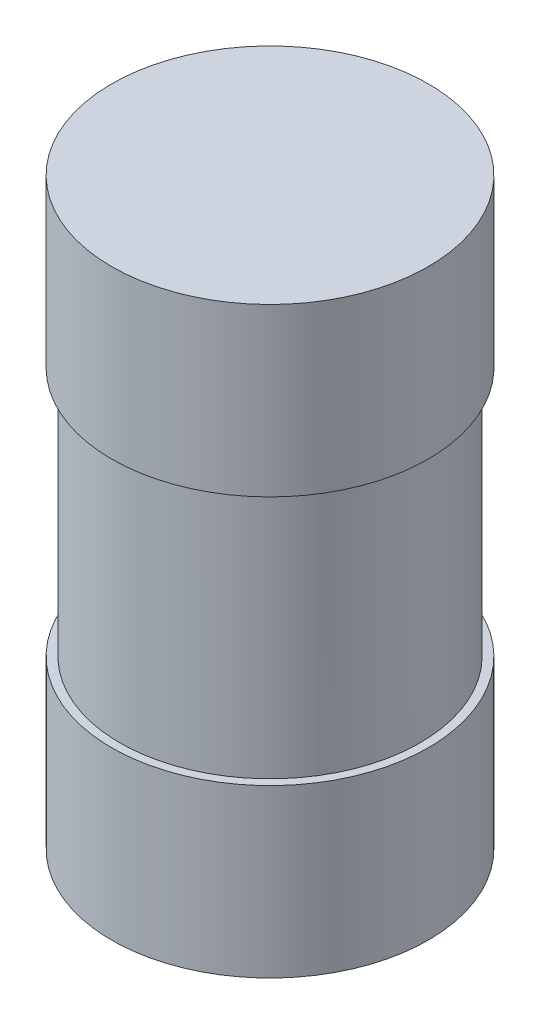
from build123d import *

# Parameters (mm, degrees)
SKETCH1_R           = 9
BOSS_EXTRUDE1_DEPTH = 35
SKETCH2_R           = 9.5
SKETCH2_R_2         = 9
BOSS_EXTRUDE2_DEPTH = 10
SKETCH3_R           = 9.5
SKETCH3_R_2         = 9
BOSS_EXTRUDE3_DEPTH = 10


with BuildPart() as part:
    # Sketch1 → Boss-Extrude1 (new body)
    with BuildSketch(Plane(origin=(0, 0, 0), x_dir=(1, 0, 0), z_dir=(0, 1, 0))):
        Circle(SKETCH1_R)
    extrude(amount=BOSS_EXTRUDE1_DEPTH)

    # Sketch2 → Boss-Extrude2 (add)
    with BuildSketch(Plane(origin=(0, 35, 0), x_dir=(1, 0, 0), z_dir=(0, 1, 0))):
        Circle(SKETCH2_R)
        Circle(SKETCH2_R_2, mode=Mode.SUBTRACT)
    extrude(amount=-BOSS_EXTRUDE2_DEPTH)

    # Sketch3 → Boss-Extrude3 (add)
    with BuildSketch(Plane(origin=(0, 0, 0), x_dir=(-1, 0, 0), z_dir=(0, -1, 0))):
        Circle(SKETCH3_R)
        Circle(SKETCH3_R_2, mode=Mode.SUBTRACT)
    extrude(amount=-BOSS_EXTRUDE3_DEPTH)


solid = part.part
